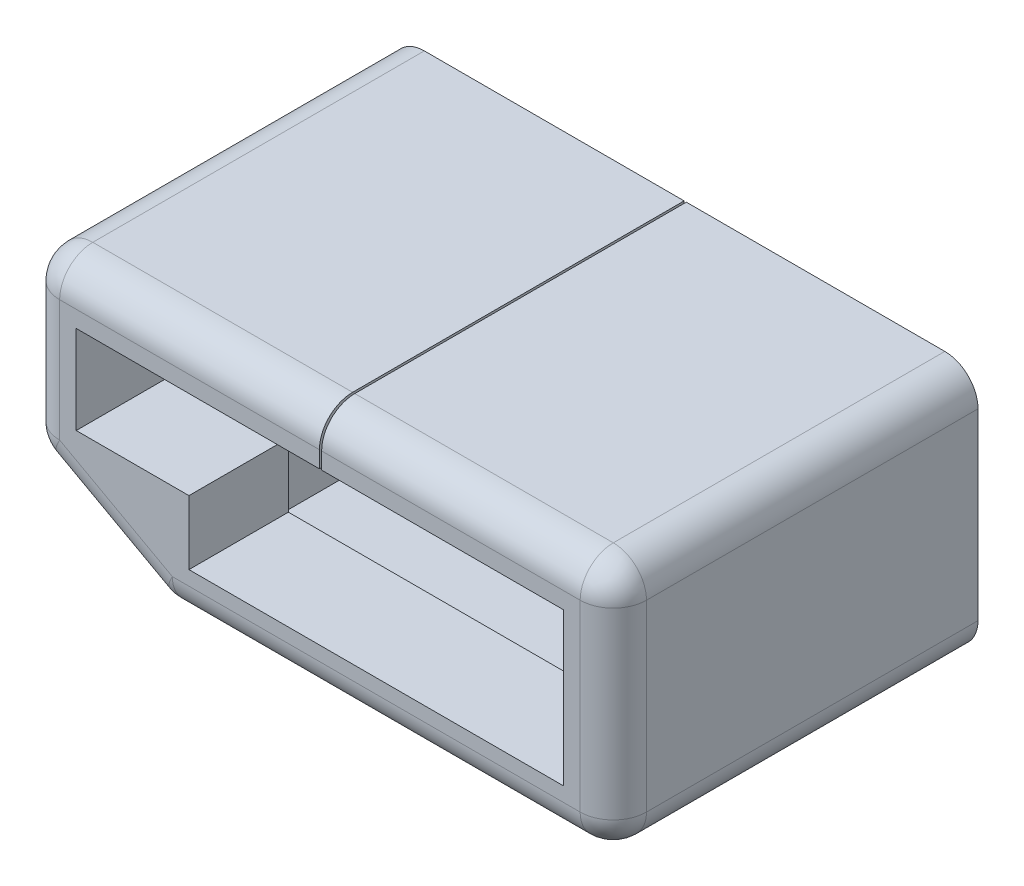
from build123d import *

# Parameters (mm, degrees)
SALIENTE_EXTRUIR1_DEPTH = 12
SALIENTE_EXTRUIR2_DEPTH = 4.5
CORTAR_EXTRUIR1_DEPTH   = 17
REDONDEO1_R             = 1.5


with BuildPart() as part:
    # Croquis1 → Saliente-Extruir1 (new body)
    with BuildSketch(Plane.XY):
        with BuildLine():
            Line((-6.703786212, -4.139854541), (11.746213788, -4.139854541))
            Line((11.746213788, -4.139854541), (11.746213788, 4.160145459))
            Line((11.746213788, 4.160145459), (0.05, 4.160145459))
            Line((0.05, 4.160145459), (0.05, 5.660145459))
            Line((0.05, 5.660145459), (11.746213788, 5.660145459))
            ThreePointArc((11.746213788, 5.660145459), (12.806873959, 5.220805631), (13.246213788, 4.160145459))
            Line((13.246213788, 4.160145459), (13.246213788, -4.139854541))
            ThreePointArc((13.246213788, -4.139854541), (12.806873959, -5.200514713), (11.746213788, -5.639854541))
            Line((11.746213788, -5.639854541), (-11.803786212, -5.639854541))
            ThreePointArc((-11.803786212, -5.639854541), (-12.864446384, -5.200514713), (-13.303786212, -4.139854541))
            Line((-13.303786212, -4.139854541), (-13.303786212, 4.160145459))
            ThreePointArc((-13.303786212, 4.160145459), (-12.864446384, 5.220805631), (-11.803786212, 5.660145459))
            Line((-11.803786212, 5.660145459), (-0.05, 5.660145459))
            Line((-0.05, 5.660145459), (-0.05, 4.160145459))
            Line((-0.05, 4.160145459), (-11.803786212, 4.160145459))
            Line((-11.803786212, 4.160145459), (-11.803786212, -1.339854541))
            Line((-11.803786212, -1.339854541), (-6.703786212, -1.339854541))
            Line((-6.703786212, -1.339854541), (-6.703786212, -4.139854541))
        make_face()
    extrude(amount=SALIENTE_EXTRUIR1_DEPTH)

    # Croquis2 → Saliente-Extruir2 (add)
    with BuildSketch(Plane.XY.offset(12)):
        with BuildLine():
            Line((-11.803786212, -5.639854541), (11.746213788, -5.639854541))
            ThreePointArc((11.746213788, -5.639854541), (12.806873959, -5.200514713), (13.246213788, -4.139854541))
            Line((13.246213788, -4.139854541), (13.246213788, 4.160145459))
            ThreePointArc((13.246213788, 4.160145459), (12.806873959, 5.220805631), (11.746213788, 5.660145459))
            Line((11.746213788, 5.660145459), (0.05, 5.660145459))
            Line((0.05, 5.660145459), (0.05, 3.410145459))
            Line((0.05, 3.410145459), (10.996213788, 3.410145459))
            Line((10.996213788, 3.410145459), (10.996213788, -3.489854541))
            Line((10.996213788, -3.489854541), (-5.953786212, -3.489854541))
            Line((-5.953786212, -3.489854541), (-5.953786212, -0.589854541))
            Line((-5.953786212, -0.589854541), (-11.053786212, -0.589854541))
            Line((-11.053786212, -0.589854541), (-11.053786212, 3.410145459))
            Line((-11.053786212, 3.410145459), (-10.745057731, 3.410145459))
            Line((-10.745057731, 3.410145459), (-0.05, 3.410145459))
            Line((-0.05, 3.410145459), (-0.05, 5.660145459))
            Line((-0.05, 5.660145459), (-11.803786212, 5.660145459))
            ThreePointArc((-11.803786212, 5.660145459), (-12.864446384, 5.220805631), (-13.303786212, 4.160145459))
            Line((-13.303786212, 4.160145459), (-13.303786212, -4.139854541))
            ThreePointArc((-13.303786212, -4.139854541), (-12.864446384, -5.200514713), (-11.803786212, -5.639854541))
        make_face()
    extrude(amount=SALIENTE_EXTRUIR2_DEPTH)

    # Croquis3 → Cortar-Extruir1 (cut)
    with BuildSketch(Plane(origin=(0, 0, 0), x_dir=(-1, 0, 0), z_dir=(0, 0, -1))):
        with BuildLine():
            Line((7.425674431, -5.454722367), (12.525674431, -2.654722367))
            ThreePointArc((12.525674431, -2.654722367), (13.094683638, -2.103781132), (13.303786212, -1.339854541))
            Line((13.303786212, -1.339854541), (14.985773561, -1.339854541))
            Line((14.985773561, -1.339854541), (14.985773561, -7.3319768))
            Line((14.985773561, -7.3319768), (6.703786212, -7.3319768))
            Line((6.703786212, -7.3319768), (6.703786212, -5.639854541))
            ThreePointArc((6.703786212, -5.639854541), (7.076410863, -5.592834537), (7.425674431, -5.454722367))
        make_face()
    extrude(amount=-CORTAR_EXTRUIR1_DEPTH, mode=Mode.SUBTRACT)

    # Redondeo1
    redondeo1_edges = [part.edges().sort_by_distance(p)[0] for p in [
        (12.806873959, -5.200514713, 16.5),
        (13.246213788, 0.010145459, 16.5),
        (12.806873959, 5.220805631, 16.5),
        (5.898106894, 5.660145459, 16.5),
        (-5.926893106, 5.660145459, 16.5),
        (-12.864446384, 5.220805631, 16.5),
        (-13.303786212, 1.410145459, 16.5),
        (2.521213788, -5.639854541, 16.5),
        (-13.094683638, -2.103781132, 16.5),
        (-9.975674431, -4.054722367, 16.5),
        (-7.076410863, -5.592834537, 16.5),
    ]]
    fillet(redondeo1_edges, radius=REDONDEO1_R)


solid = part.part
